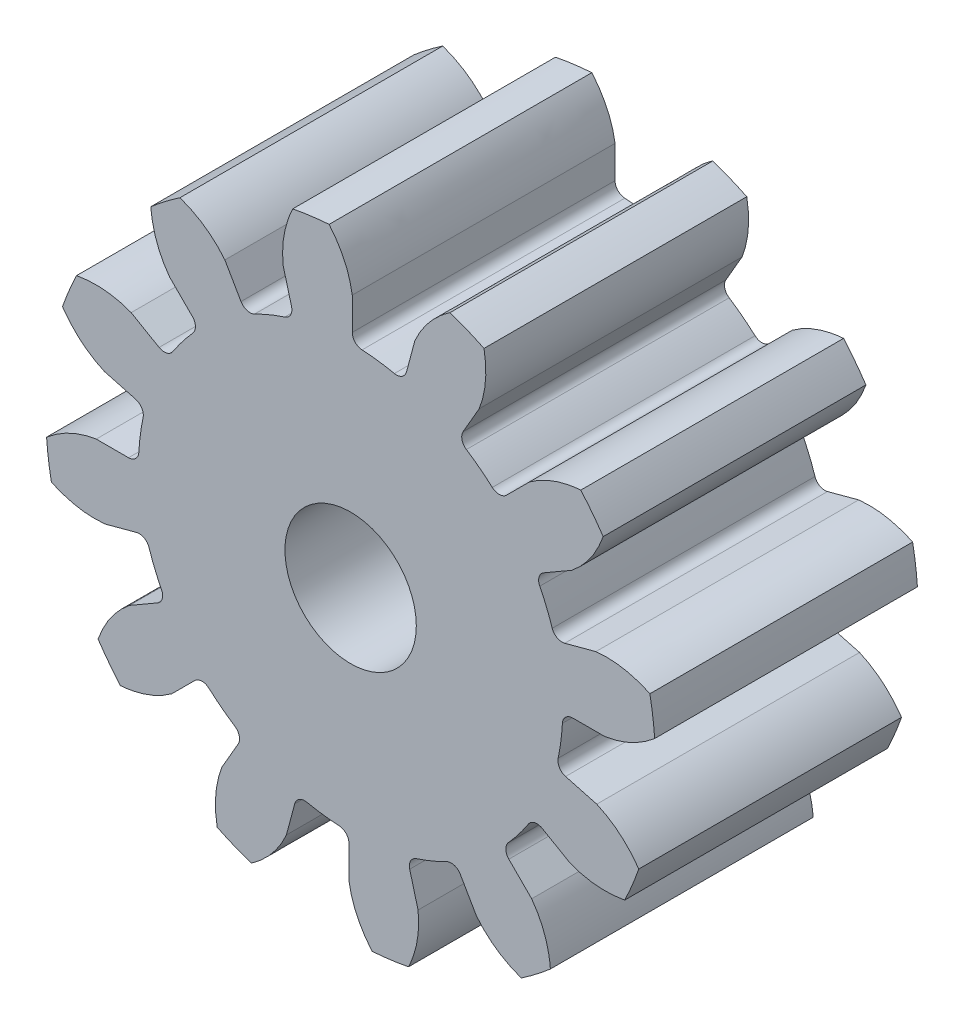
from build123d import *

# Parameters (mm, degrees)
SKETCH1_R                = 7.366
BOSS_EXTRUDE1_DEPTH      = 6.35
CUT_EXTRUDE1_DEPTH       = 7.35
FILLET1_R                = 0.2493645
CIRPATTERN1_COUNT        = 12
FILLET1_OF_CIRPATTERN1_R = 0.2493645
SKETCH5_R                = 1.5875
CUT_EXTRUDE2_DEPTH       = 7.3500049


with BuildPart() as part:
    # Sketch1 → Boss-Extrude1 (new body)
    with BuildSketch(Plane.XY):
        Circle(SKETCH1_R)
    extrude(amount=-BOSS_EXTRUDE1_DEPTH)

    # Sketch4 → Cut-Extrude1 (cut, through all)
    with BuildSketch(Plane.XY):
        with BuildLine():
            Line((0.039954341, 6.147607683), (0.039954341, 5.125352605))
            ThreePointArc((0.039954341, 5.125352605), (0.669014641, 5.081658694), (1.287948975, 4.961050606))
            Line((1.287948975, 4.961050606), (1.552528662, 5.948473025))
            add(Edge.make_bspline(
                [(2.447477101, 6.992325707), (1.830193727, 6.582214897), (1.552528662, 5.948473025)],
                knots=[0, 0, 0, 1, 1, 1], degree=2))
            ThreePointArc((2.447477101, 6.992325707), (0.966978152, 7.344910905), (-0.554329756, 7.387522012))
            add(Edge.make_bspline(
                [(-0.554329756, 7.387522012), (-0.064224631, 6.831620395), (0.039954341, 6.147607683)],
                knots=[0, 0, 0, 1, 1, 1], degree=2))
        make_face()
    cut_extrude1 = extrude(amount=-CUT_EXTRUDE1_DEPTH, mode=Mode.SUBTRACT)

    # Fillet1
    fillet1_edges = [part.edges().sort_by_distance(p)[0] for p in [
        (1.287948975, 4.961050606, -3.175),
        (0.039954341, 5.125352605, -3.175),
    ]]
    fillet(fillet1_edges, radius=FILLET1_R)

    # CirPattern1: Cut-Extrude1 ×12 about axis
    cirpattern1_axis = Axis((0, 0, -6.35), (0, 0, 1))
    for i in range(1, CIRPATTERN1_COUNT):
        add(cut_extrude1.rotate(cirpattern1_axis, i * 360 / CIRPATTERN1_COUNT), mode=Mode.SUBTRACT)

    # Fillet1 of CirPattern1
    fillet1_of_cirpattern1_edges = [part.edges().sort_by_distance(p)[0] for p in [
        (-1.365128772, 4.940370341, -3.175),
        (-2.528074828, 4.45866273, -3.175),
        (-3.652421367, 3.595921834, -3.175),
        (-4.418708389, 2.597277777, -3.175),
        (-4.961050606, 1.287948975, -3.175),
        (-5.125352605, 0.039954341, -3.175),
        (-4.940370341, -1.365128772, -3.175),
        (-4.45866273, -2.528074828, -3.175),
        (-3.595921834, -3.652421367, -3.175),
        (-2.597277777, -4.418708389, -3.175),
        (-1.287948975, -4.961050606, -3.175),
        (-0.039954341, -5.125352605, -3.175),
        (1.365128772, -4.940370341, -3.175),
        (2.528074828, -4.45866273, -3.175),
        (3.652421367, -3.595921834, -3.175),
        (4.418708389, -2.597277777, -3.175),
        (4.961050606, -1.287948975, -3.175),
        (5.125352605, -0.039954341, -3.175),
        (4.940370341, 1.365128772, -3.175),
        (4.45866273, 2.528074828, -3.175),
        (3.595921834, 3.652421367, -3.175),
        (2.597277777, 4.418708389, -3.175),
    ]]
    fillet(fillet1_of_cirpattern1_edges, radius=FILLET1_OF_CIRPATTERN1_R)

    # Sketch5 → Cut-Extrude2 (cut, through all)
    with BuildSketch(Plane.XY):
        Circle(SKETCH5_R)
    extrude(amount=-CUT_EXTRUDE2_DEPTH, mode=Mode.SUBTRACT)


solid = part.part
